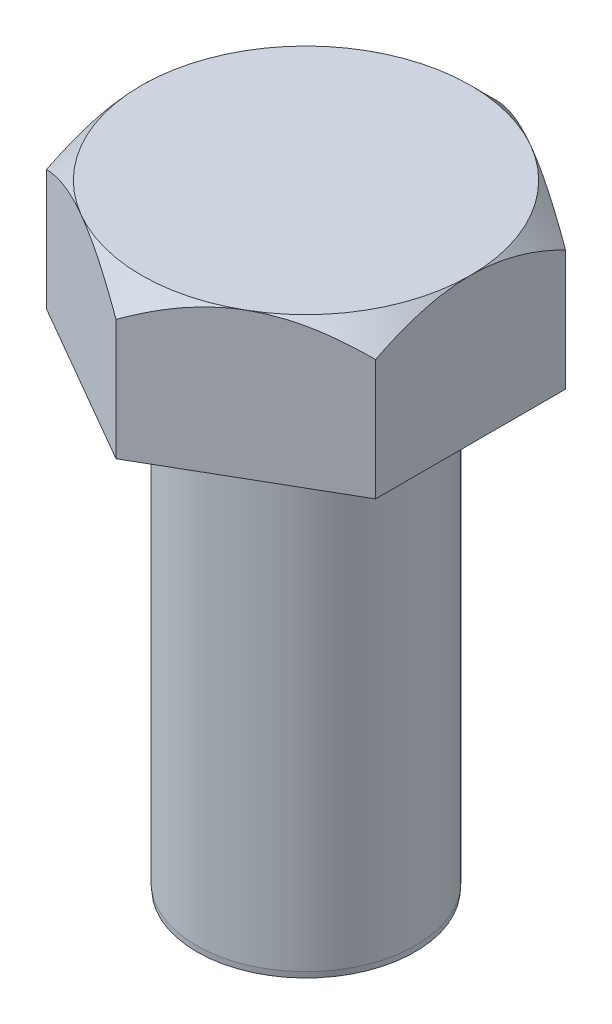
from build123d import *

# Parameters (mm, degrees)
BOSS_EXTRUDE1_DEPTH = 6.35
SKETCH2_R           = 4.7625
BOSS_EXTRUDE2_DEPTH = 20.32
SKETCH3_OUTSIDE_W   = 63.834
SKETCH3_OUTSIDE_H   = 66.046
SKETCH3_OUTSIDE_R   = 7.1501
CUT_EXTRUDE1_DEPTH  = 20.32
CUT_EXTRUDE1_TAPER  = 45
CHAMFER1_SIZE       = 0.254
CHAMFER1_SIZE2      = 0.022222121


with BuildPart() as part:
    # Sketch1 → Boss-Extrude1 (new body)
    with BuildSketch(Plane(origin=(0, 0, 0), x_dir=(1, 0, 0), z_dir=(0, 1, 0))):
        Polygon((0, 8.256224319), (-7.1501, 4.12811216), (-7.1501, -4.12811216), (0, -8.256224319), (7.1501, -4.12811216), (7.1501, 4.12811216), align=None)
    extrude(amount=BOSS_EXTRUDE1_DEPTH)

    # Sketch2 → Boss-Extrude2 (add)
    with BuildSketch(Plane.XZ):
        Circle(SKETCH2_R)
    extrude(amount=BOSS_EXTRUDE2_DEPTH)

    # Sketch3 outside → Cut-Extrude1 (cut)
    with BuildSketch(Plane(origin=(0, 6.35, 0), x_dir=(1, 0, 0), z_dir=(0, 1, 0))):
        Rectangle(SKETCH3_OUTSIDE_W, SKETCH3_OUTSIDE_H)
        Circle(SKETCH3_OUTSIDE_R, mode=Mode.SUBTRACT)
    extrude(amount=-CUT_EXTRUDE1_DEPTH, taper=CUT_EXTRUDE1_TAPER, mode=Mode.SUBTRACT)

    # Chamfer1
    chamfer1_edges = [part.edges().sort_by_distance(p)[0] for p in [
        (-4.7625, -20.32, 0),
    ]]
    chamfer1_side = [part.faces().sort_by_distance(p)[0] for p in [
        (-4.7625, -10.16, 0),
    ]]
    chamfer(chamfer1_edges, length=CHAMFER1_SIZE, length2=CHAMFER1_SIZE2, reference=chamfer1_side[0])


solid = part.part
